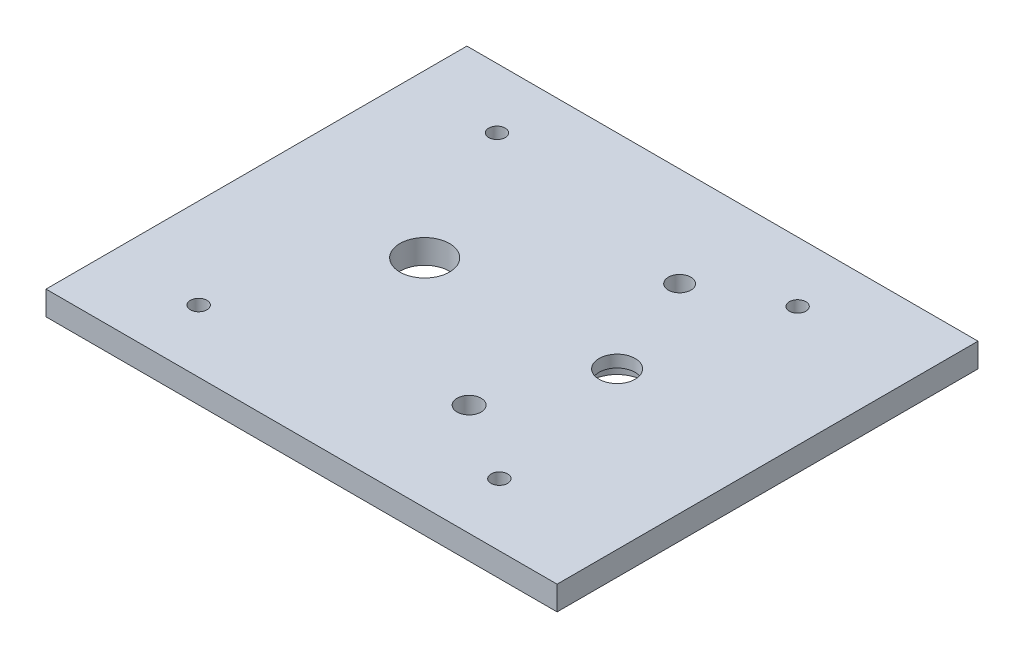
from build123d import *

# Parameters (mm, degrees)
SKETCH1_W           = 85
SKETCH1_H           = 70
SKETCH1_R           = 1.375
SKETCH1_R_2         = 2
SKETCH1_R_3         = 1.875
SKETCH1_R_4         = 4.125
SKETCH1_R_5         = 3
BOSS_EXTRUDE4_DEPTH = 4
SKETCH1_7_R         = 4.5
CUT_EXTRUDE2_DEPTH  = 2


with BuildPart() as part:
    # Sketch1 → Boss-Extrude4 (new body)
    with BuildSketch(Plane(origin=(0, 0, 0), x_dir=(1, 0, 0), z_dir=(0, 1, 0))):
        Rectangle(SKETCH1_W, SKETCH1_H)
        with Locations((-27.5, -24.60667729)):
            Circle(SKETCH1_R, mode=Mode.SUBTRACT)
        with Locations((22.5, -24.60667729)):
            Circle(SKETCH1_R, mode=Mode.SUBTRACT)
        with Locations((9.401398241, -16.528956449)):
            Circle(SKETCH1_R_2, mode=Mode.SUBTRACT)
        with Locations((-27.5, 25)):
            Circle(SKETCH1_R, mode=Mode.SUBTRACT)
        with Locations((9.407211052, 18.471043068)):
            Circle(SKETCH1_R_3, mode=Mode.SUBTRACT)
        with Locations((22.5, 25)):
            Circle(SKETCH1_R, mode=Mode.SUBTRACT)
        with Locations((-15.52, 1)):
            Circle(SKETCH1_R_4, mode=Mode.SUBTRACT)
        with Locations((16.478339488, 0.999882702)):
            Circle(SKETCH1_R_5, mode=Mode.SUBTRACT)
    extrude(amount=BOSS_EXTRUDE4_DEPTH)

    # Sketch1_7 → Cut-Extrude2 (cut)
    with BuildSketch(Plane(origin=(0, 0, 0), x_dir=(1, 0, 0), z_dir=(0, 1, 0))):
        with Locations((16.478339488, 0.999882702)):
            Circle(SKETCH1_7_R)
    extrude(amount=CUT_EXTRUDE2_DEPTH, mode=Mode.SUBTRACT)


solid = part.part
